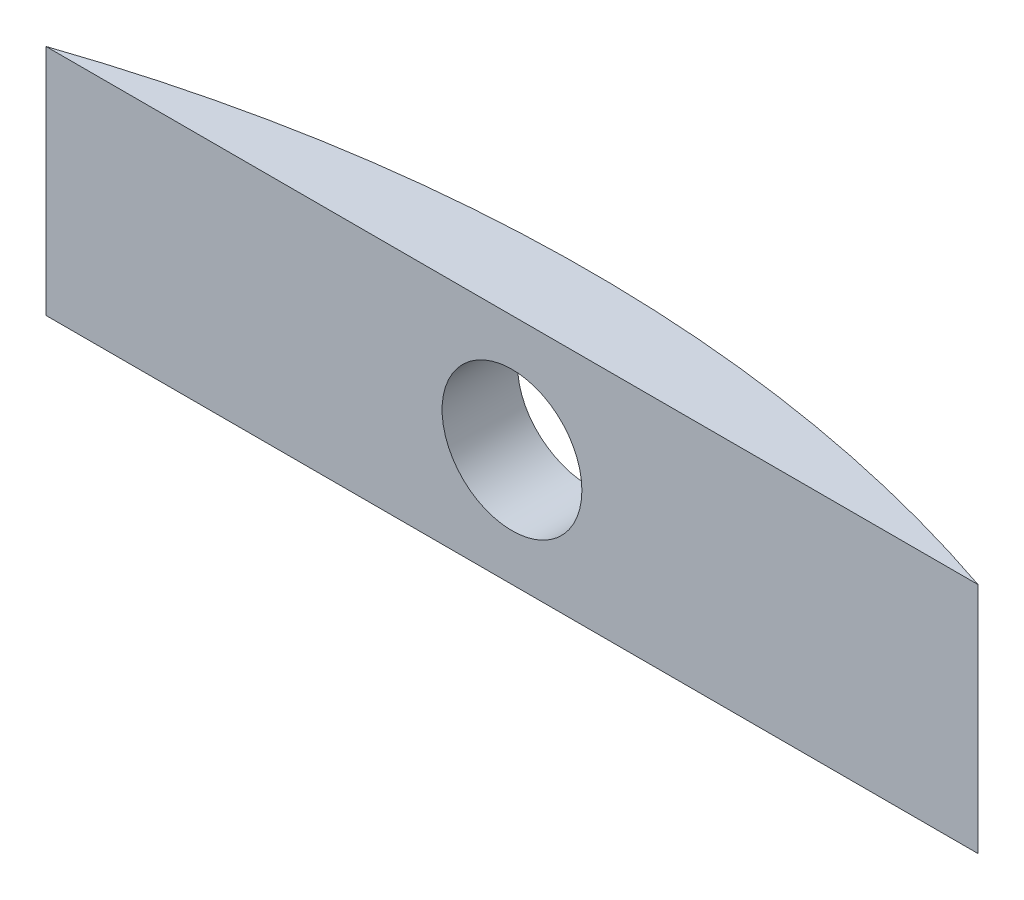
from build123d import *

# Parameters (mm, degrees)
BOSS_EXTRUDE1_DEPTH = 10
CUT_EXTRUDE1_REACH  = 5.314
SKETCH2_R           = 3


with BuildPart() as part:
    # Sketch1 → Boss-Extrude1 (new body)
    with BuildSketch(Plane(origin=(0, 0, 0), x_dir=(1, 0, 0), z_dir=(0, 1, 0))):
        with BuildLine():
            Line((0, 0), (40, 0))
            ThreePointArc((40, 0), (20, 3.314396996), (0, 0))
        make_face()
    extrude(amount=BOSS_EXTRUDE1_DEPTH)

    # Sketch2 → Cut-Extrude1 (cut, up to next)
    with BuildSketch(Plane.XY, mode=Mode.PRIVATE) as cut_extrude1_sk1:
        with Locations((20, 5)):
            Circle(SKETCH2_R)
    cut_extrude1_tool1 = extrude(cut_extrude1_sk1.sketch, amount=-CUT_EXTRUDE1_REACH, mode=Mode.PRIVATE) & part.part
    add(cut_extrude1_tool1.solids().sort_by_distance((20, 5, 0))[0], mode=Mode.SUBTRACT)


solid = part.part
